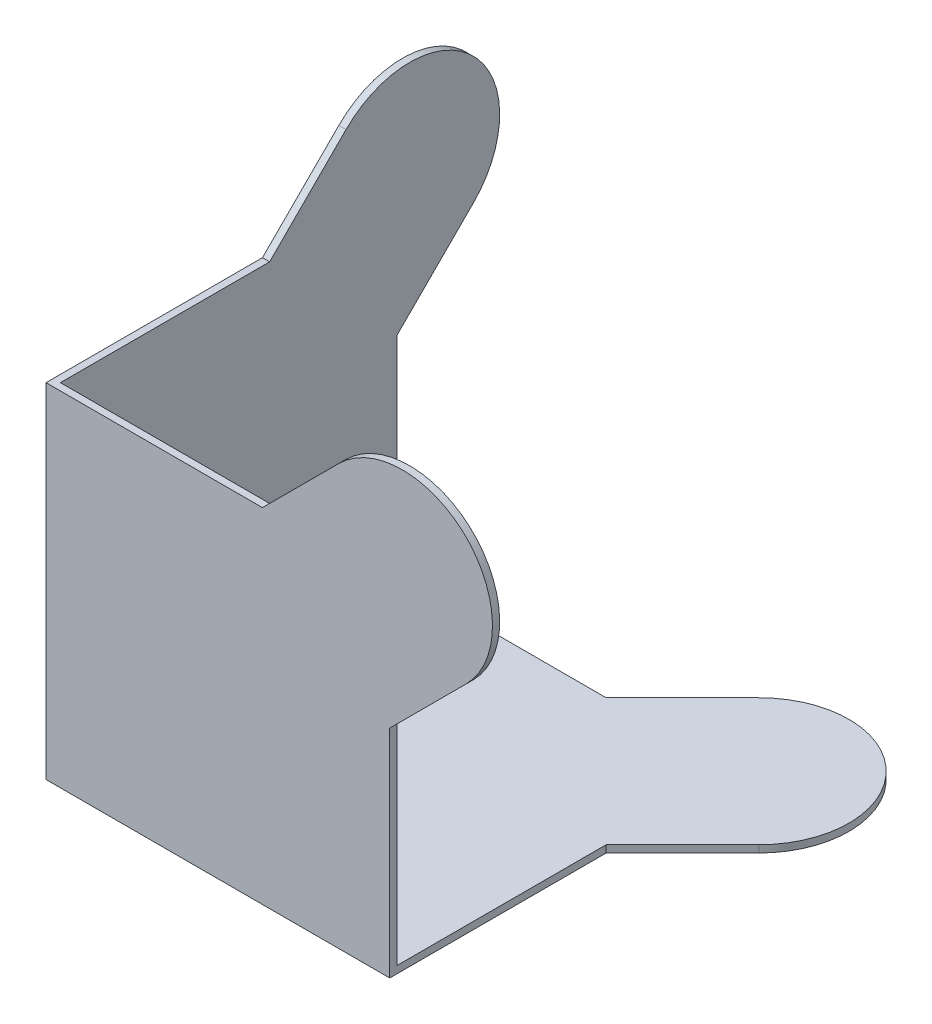
from build123d import *

# Parameters (mm, degrees)
BOSS_EXTRUDE1_DEPTH = 1
BOSS_EXTRUDE2_DEPTH = 1
BOSS_EXTRUDE3_DEPTH = 1


with BuildPart() as part:
    # Sketch1 → Boss-Extrude1 (new body)
    with BuildSketch(Plane.XY):
        with BuildLine():
            Line((30.054563517, 47.732233047), (40.661165235, 58.338834765))
            ThreePointArc((40.661165235, 58.338834765), (58.338834765, 58.338834765), (58.338834765, 40.661165235))
            Line((58.338834765, 40.661165235), (47.732233047, 30.054563517))
            Line((47.732233047, 30.054563517), (47.732233047, 0))
            Line((47.732233047, 0), (0, 0))
            Line((0, 0), (0, 47.732233047))
            Line((0, 47.732233047), (30.054563517, 47.732233047))
        make_face()
    extrude(amount=-BOSS_EXTRUDE1_DEPTH)

    # Sketch2 → Boss-Extrude2 (add)
    with BuildSketch(Plane(origin=(0, 0, 0), x_dir=(0, 0, -1), z_dir=(1, 0, 0))):
        with BuildLine():
            Line((30.054563517, 47.732233047), (40.661165235, 58.338834765))
            ThreePointArc((40.661165235, 58.338834765), (58.338834765, 58.338834765), (58.338834765, 40.661165235))
            Line((58.338834765, 40.661165235), (47.732233047, 30.054563517))
            Line((47.732233047, 30.054563517), (47.732233047, 0))
            Line((47.732233047, 0), (0, 0))
            Line((0, 0), (0, 47.732233047))
            Line((0, 47.732233047), (30.054563517, 47.732233047))
        make_face()
    extrude(amount=BOSS_EXTRUDE2_DEPTH)

    # Sketch3 → Boss-Extrude3 (add)
    with BuildSketch(Plane(origin=(0, 0, 0), x_dir=(1, 0, 0), z_dir=(0, 1, 0))):
        with BuildLine():
            Line((30.054563517, 47.732233047), (40.661165235, 58.338834765))
            ThreePointArc((40.661165235, 58.338834765), (58.338834765, 58.338834765), (58.338834765, 40.661165235))
            Line((58.338834765, 40.661165235), (47.732233047, 30.054563517))
            Line((47.732233047, 30.054563517), (47.732233047, 0))
            Line((47.732233047, 0), (0, 0))
            Line((0, 0), (0, 47.732233047))
            Line((0, 47.732233047), (30.054563517, 47.732233047))
        make_face()
    extrude(amount=BOSS_EXTRUDE3_DEPTH)


solid = part.part
